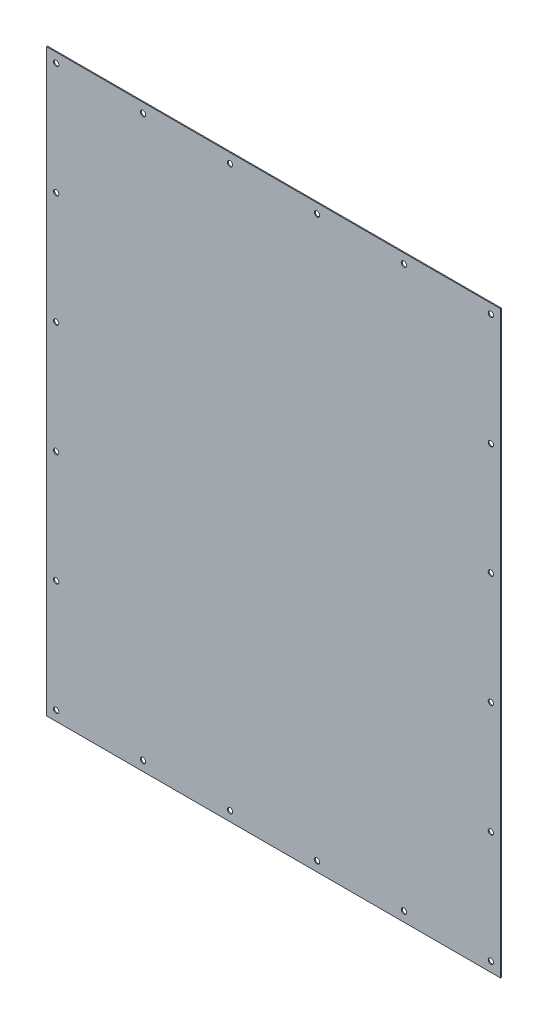
from build123d import *

# Parameters (mm, degrees)
SKETCH_1_W         = 470
SKETCH_1_H         = 600
EXTRUDE_1_DEPTH    = 1
HOLE_WIZARD_M5_1_D = 5.5


with BuildPart() as part:
    # 스케치1 → 보스-돌출1 (new body)
    with BuildSketch(Plane.XY):
        Rectangle(SKETCH_1_W, SKETCH_1_H)
    extrude(amount=EXTRUDE_1_DEPTH)

    # M5 여유 구멍1 (through all)
    with Locations(Plane.XY.offset(1)):
        with Locations((-225, 290), (-135, 290), (-45, 290), (45, 290), (135, 290), (225, 290), (225, 174), (225, 58), (225, -58), (225, -174), (225, -290), (135, -290), (45, -290), (-45, -290), (-135, -290), (-225, -290), (-225, -174), (-225, -58), (-225, 174), (-225, 58)):
            Hole(HOLE_WIZARD_M5_1_D / 2)


solid = part.part
